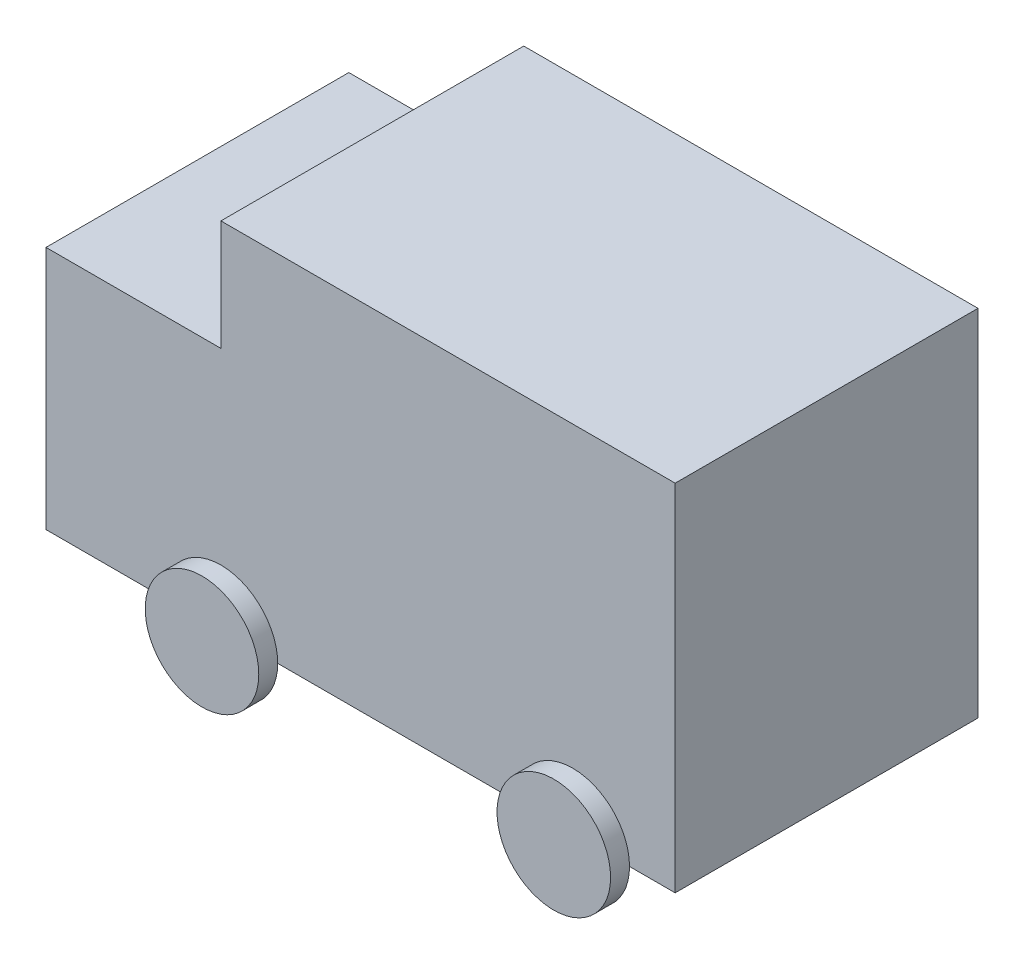
from build123d import *

# Parameters (mm, degrees)
SKETCH1_W           = 3657.6
SKETCH1_H           = 2438.4
BOSS_EXTRUDE1_DEPTH = 2857
SKETCH2_W           = 1408.446340605
SKETCH2_H           = 2438.4
BOSS_EXTRUDE2_DEPTH = 1968
SKETCH3_R           = 457.2
BOSS_EXTRUDE3_DEPTH = 152.4


with BuildPart() as part:
    # Sketch1 → Boss-Extrude1 (new body)
    with BuildSketch(Plane(origin=(0, 0, 0), x_dir=(1, 0, 0), z_dir=(0, 1, 0))):
        with Locations((1828.8, 0)):
            Rectangle(SKETCH1_W, SKETCH1_H)
    extrude(amount=BOSS_EXTRUDE1_DEPTH)

    # Sketch2 → Boss-Extrude2 (add)
    with BuildSketch(Plane(origin=(0, 0, 0), x_dir=(1, 0, 0), z_dir=(0, 1, 0))):
        with Locations((-704.223170303, 0)):
            Rectangle(SKETCH2_W, SKETCH2_H)
    extrude(amount=BOSS_EXTRUDE2_DEPTH)

    # Sketch3 → Boss-Extrude3 (add)
    with BuildSketch(Plane.XY.offset(1219.2)):
        Circle(SKETCH3_R)
        with Locations((2832.801463022, 0)):
            Circle(SKETCH3_R)
    boss_extrude3 = extrude(amount=BOSS_EXTRUDE3_DEPTH)

    # Mirror1: Boss-Extrude3 across plane
    add(boss_extrude3.mirror(Plane.XY))


solid = part.part
